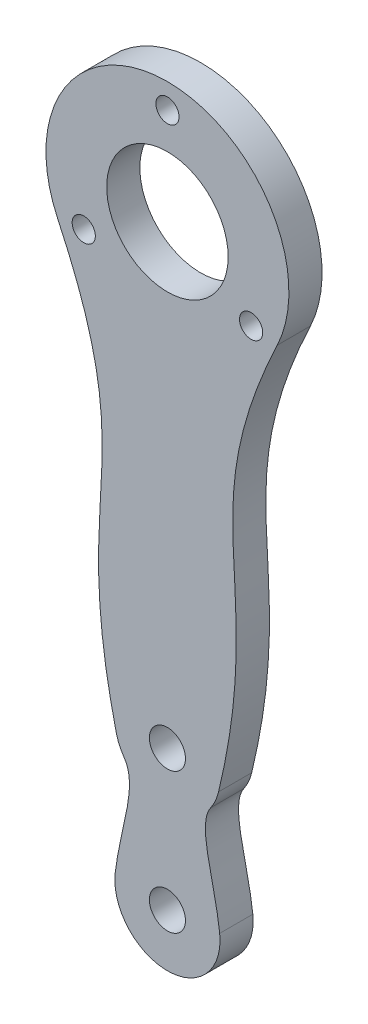
from build123d import *

# Parameters (mm, degrees)
SKETCH1_R           = 2.1
SKETCH1_R_2         = 11
SKETCH1_R_3         = 3.2639
BOSS_EXTRUDE1_DEPTH = 6


with BuildPart() as part:
    # Sketch1 → Boss-Extrude1 (new body)
    with BuildSketch(Plane.XY):
        with BuildLine():
            ThreePointArc((19.889218642, 15.996863194), (0, 47.4), (-19.889218642, 15.996863194))
            add(Edge.make_bspline(
                [(-19.889218642, 15.996863194), (-3.976229329, -17.66179032), (-18.147711497, -22.281552166), (-9.262906138, -59.369052697)],
                knots=[0, 0, 0, 0, 1, 1, 1, 1], degree=3))
            ThreePointArc((-9.262906138, -59.369052697), (-8.692742138, -61.0438232), (-7.822687238, -62.584260701))
            add(Edge.make_bspline(
                [(-9.462887275, -81.464003027), (-8.561282023, -73.607821952), (-5.270691934, -66.257890325), (-7.822687238, -62.584260701)],
                knots=[0, 0, 0, 0, 1, 1, 1, 1], degree=3))
            ThreePointArc((-9.462887275, -81.464003027), (0, -92.075), (9.462887275, -81.464003027))
            add(Edge.make_bspline(
                [(9.462887275, -81.464003027), (8.561282023, -73.607821952), (5.270691934, -66.257890325), (7.822687238, -62.584260701)],
                knots=[0, 0, 0, 0, 1, 1, 1, 1], degree=3))
            ThreePointArc((7.822687238, -62.584260701), (8.692742138, -61.0438232), (9.262906138, -59.369052697))
            add(Edge.make_bspline(
                [(19.889218642, 15.996863194), (3.976229329, -17.66179032), (18.147711497, -22.281552166), (9.262906138, -59.369052697)],
                knots=[0, 0, 0, 0, 1, 1, 1, 1], degree=3))
        make_face()
        with Locations((-15.155444566, 16.65)):
            Circle(SKETCH1_R, mode=Mode.SUBTRACT)
        with Locations((0, 42.9)):
            Circle(SKETCH1_R, mode=Mode.SUBTRACT)
        with Locations((0, 25.4)):
            Circle(SKETCH1_R_2, mode=Mode.SUBTRACT)
        with Locations((15.155444566, 16.65)):
            Circle(SKETCH1_R, mode=Mode.SUBTRACT)
        with Locations((0, -57.15)):
            Circle(SKETCH1_R_3, mode=Mode.SUBTRACT)
        with Locations((0, -82.55)):
            Circle(SKETCH1_R_3, mode=Mode.SUBTRACT)
    extrude(amount=BOSS_EXTRUDE1_DEPTH)


solid = part.part
